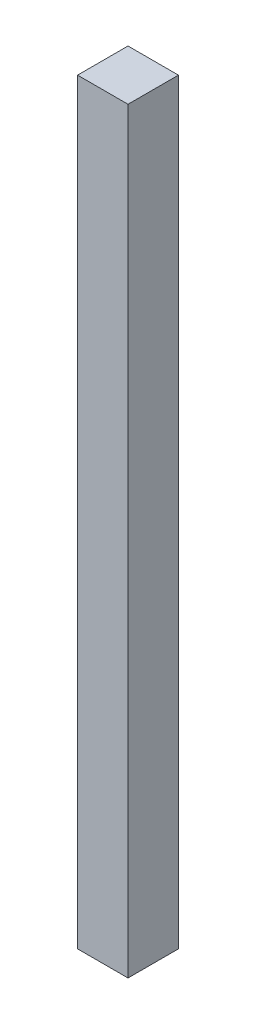
from build123d import *

# Parameters (mm, degrees)
SKETCH1_W           = 15
SKETCH1_H           = 15
BOSS_EXTRUDE1_DEPTH = 225


with BuildPart() as part:
    # Sketch1 → Boss-Extrude1 (new body)
    with BuildSketch(Plane(origin=(0, 0, 0), x_dir=(1, 0, 0), z_dir=(0, 1, 0))):
        Rectangle(SKETCH1_W, SKETCH1_H)
    extrude(amount=BOSS_EXTRUDE1_DEPTH)


solid = part.part
